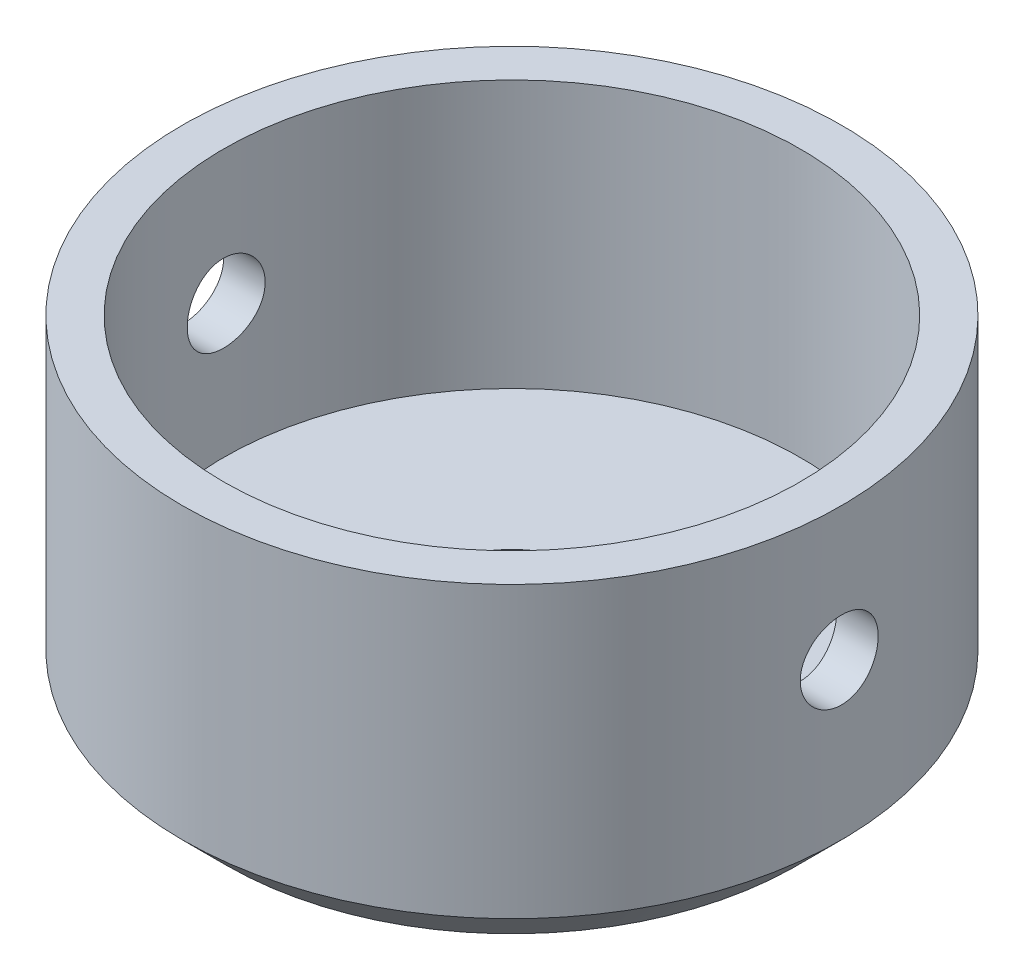
from build123d import *

# Parameters (mm, degrees)
SKETCH1_R               = 14.8
BOSS_EXTRUDE1_DEPTH     = 15
SKETCH2_R               = 12.95
CUT_EXTRUDE1_DEPTH      = 12
SKETCH3_R               = 1.75
CUT_EXTRUDE2_DEPTH      = 15.8
CUT_EXTRUDE2_DEPTH_BACK = 15.8
SKETCH4_R               = 4.1
CUT_EXTRUDE3_DEPTH      = 16.0000001
CHAMFER1_SIZE           = 2


with BuildPart() as part:
    # Sketch1 → Boss-Extrude1 (new body)
    with BuildSketch(Plane(origin=(0, 0, 0), x_dir=(1, 0, 0), z_dir=(0, 1, 0))):
        Circle(SKETCH1_R)
    extrude(amount=BOSS_EXTRUDE1_DEPTH)

    # Sketch2 → Cut-Extrude1 (cut)
    with BuildSketch(Plane(origin=(0, 15, 0), x_dir=(1, 0, 0), z_dir=(0, 1, 0))):
        Circle(SKETCH2_R)
    extrude(amount=-CUT_EXTRUDE1_DEPTH, mode=Mode.SUBTRACT)

    # Sketch3 → Cut-Extrude2 (cut, two sides)
    with BuildSketch(Plane(origin=(0, 0, 0), x_dir=(0, 0, -1), z_dir=(1, 0, 0))) as cut_extrude2_sk:
        with Locations((0, 9)):
            Circle(SKETCH3_R)
    extrude(amount=CUT_EXTRUDE2_DEPTH, mode=Mode.SUBTRACT)
    extrude(cut_extrude2_sk.sketch, amount=-CUT_EXTRUDE2_DEPTH_BACK, mode=Mode.SUBTRACT)

    # Sketch4 → Cut-Extrude3 (cut, through all)
    with BuildSketch(Plane.XZ):
        Circle(SKETCH4_R)
    extrude(amount=-CUT_EXTRUDE3_DEPTH, mode=Mode.SUBTRACT)

    # Chamfer1
    chamfer1_edges = [part.edges().sort_by_distance(p)[0] for p in [
        (-14.8, 0, 0),
    ]]
    chamfer(chamfer1_edges, length=CHAMFER1_SIZE)


solid = part.part
